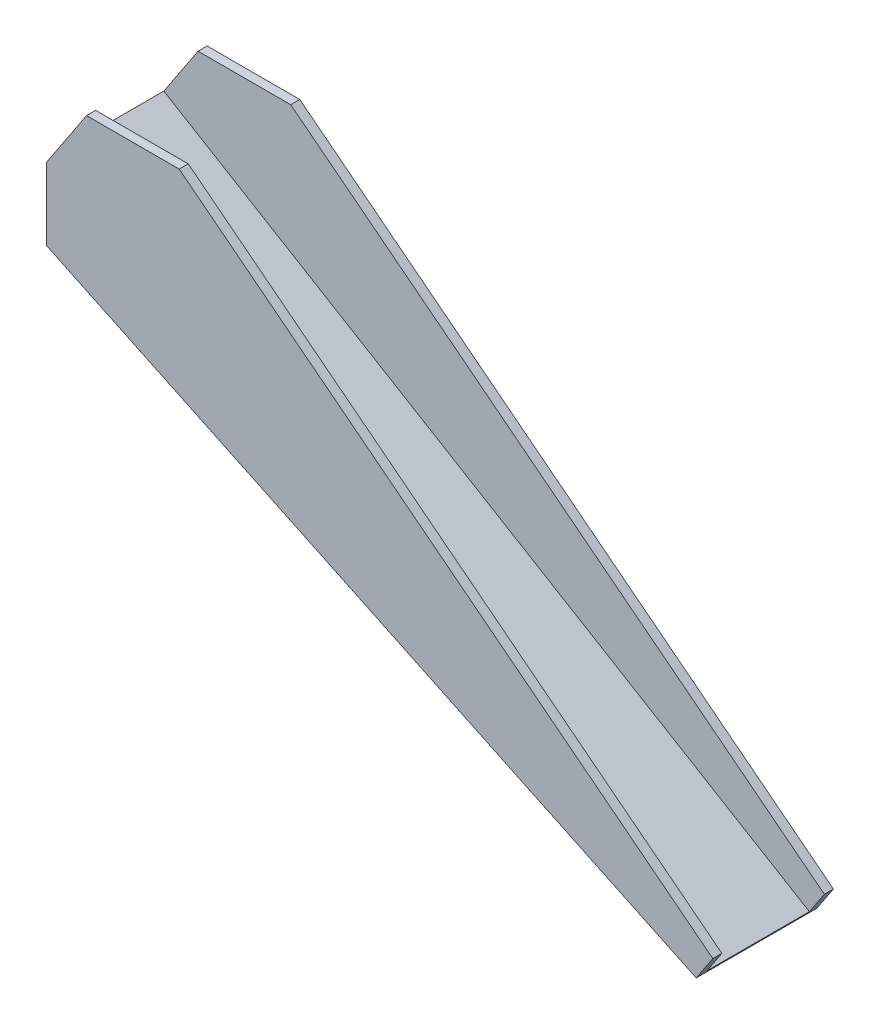
from build123d import *

# Parameters (mm, degrees)
BOSS_EXTRU_1_DEPTH                  = 10
ENL_V_START                         = 0.5
ESQUISSE3_W                         = 17
ESQUISSE3_H                         = 125.217180483
ENL_V_MAT_EXTRU_2_DEPTH             = 20
ENL_V_MAT_EXTRU_3_REACH             = 41.835
DIAM_TRE_DU_PER_AGE_5_0_5_2_D       = 5
DIAM_TRE_DU_PER_AGE_1_5_1_5_1_D     = 1.5
DIAM_TRE_DU_PER_AGE_1_5_1_5_1_DEPTH = 5
DIAM_TRE_DU_PER_AGE_1_5_1_5_1_TIP   = 0.450645464


with BuildPart() as part:
    # Esquisse1 → Boss.-Extru.1 (new body, symmetric)
    with BuildSketch(Plane.XY):
        Polygon((85.767026828, -38.334571354), (88.53088082, -34.167904687), (0, 35), (-15.366750419, 35), (-22, 25), (-22, 13), align=None)
    extrude(amount=BOSS_EXTRU_1_DEPTH, both=True)

    # Esquisse3 → Enl_v. mat.-Extru.2 (cut)
    with BuildSketch(Plane(origin=(5.827214604, 9.698113705, 0), x_dir=(0, 0, -1), z_dir=(0.515038075, 0.857167301, 0)).offset(ENL_V_START)):
        with Locations((0, -30.874957754)):
            Rectangle(ESQUISSE3_W, ESQUISSE3_H)
    extrude(amount=ENL_V_MAT_EXTRU_2_DEPTH, mode=Mode.SUBTRACT)

    # Esquisse4 → Enl_v. mat.-Extru.3 (cut, up to next)
    with BuildSketch(Plane(origin=(0, 1.5, 0), x_dir=(1, 0, 0), z_dir=(0, 1, 0)), mode=Mode.PRIVATE) as enl_v_mat_extru_3_sk1:
        with BuildLine():
            Line((0.413793103, 3.978539338), (14.75862069, 2.486587087))
            ThreePointArc((14.75862069, 2.486587087), (17, 0), (14.75862069, -2.486587087))
            Line((14.75862069, -2.486587087), (0.413793103, -3.978539338))
            ThreePointArc((0.413793103, -3.978539338), (-4, 0), (0.413793103, 3.978539338))
        make_face()
    enl_v_mat_extru_3_tool1 = extrude(enl_v_mat_extru_3_sk1.sketch, amount=-ENL_V_MAT_EXTRU_3_REACH, mode=Mode.PRIVATE) & part.part
    add(enl_v_mat_extru_3_tool1.solids().sort_by_distance((5.738323, 1.5, 0))[0], mode=Mode.SUBTRACT)

    # Diam_tre du per_age _5.0 _5_2 (through all)
    with Locations(Plane(origin=(0, 1.5, 0), x_dir=(-1, 0, 0), z_dir=(0, -1, 0))):
        with Locations((0, 0)):
            Hole(DIAM_TRE_DU_PER_AGE_5_0_5_2_D / 2)

    # Diam_tre du per_age _1.5 _1.5_1
    with Locations(Plane(origin=(0, 1.5, 0), x_dir=(-1, 0, 0), z_dir=(0, -1, 0))):
        with Locations((-14.5, 0), (-4.5, 0)):
            Hole(DIAM_TRE_DU_PER_AGE_1_5_1_5_1_D / 2, depth=DIAM_TRE_DU_PER_AGE_1_5_1_5_1_DEPTH)
            with Locations((0, 0, -(DIAM_TRE_DU_PER_AGE_1_5_1_5_1_DEPTH + DIAM_TRE_DU_PER_AGE_1_5_1_5_1_TIP / 2))):  # 118° drill point
                Cone(0, DIAM_TRE_DU_PER_AGE_1_5_1_5_1_D / 2, DIAM_TRE_DU_PER_AGE_1_5_1_5_1_TIP, mode=Mode.SUBTRACT)


solid = part.part
